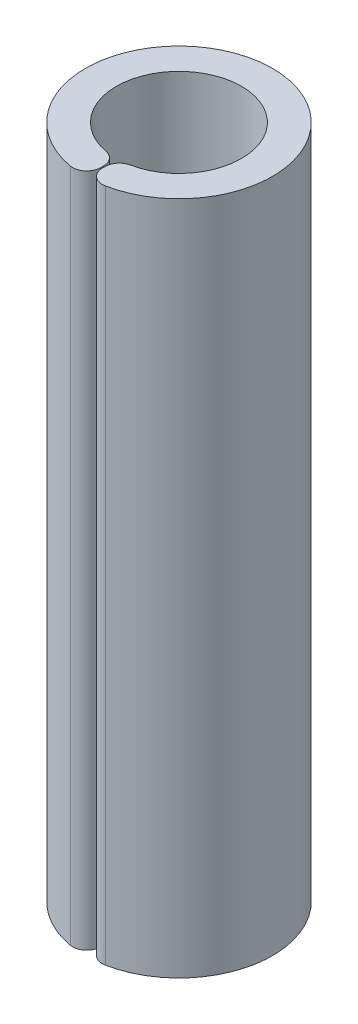
from build123d import *

# Parameters (mm, degrees)
BOSS_EXTRUDE1_DEPTH = 28.85
FILLET1_R           = 0.6


with BuildPart() as part:
    # Sketch1 → Boss-Extrude1 (new body)
    with BuildSketch(Plane(origin=(0, 0, 0), x_dir=(1, 0, 0), z_dir=(0, 1, 0))):
        with BuildLine():
            Line((0.046685187, -2.674592585), (0.069809626, -3.999390781))
            ThreePointArc((0.069809626, -3.999390781), (-0.034906142, 3.999847692), (0, -4))
            Line((0, -4), (0, -2.675))
            ThreePointArc((0, -2.675), (-0.023343482, 2.674898144), (0.046685187, -2.674592585))
        make_face()
    extrude(amount=BOSS_EXTRUDE1_DEPTH)

    # Fillet1
    fillet1_edges = [part.edges().sort_by_distance(p)[0] for p in [
        (0, 14.425, 2.675),
        (0, 14.425, 4),
        (0.069809626, 14.425, 3.999390781),
        (0.046685187, 14.425, 2.674592585),
    ]]
    fillet(fillet1_edges, radius=FILLET1_R)


solid = part.part
